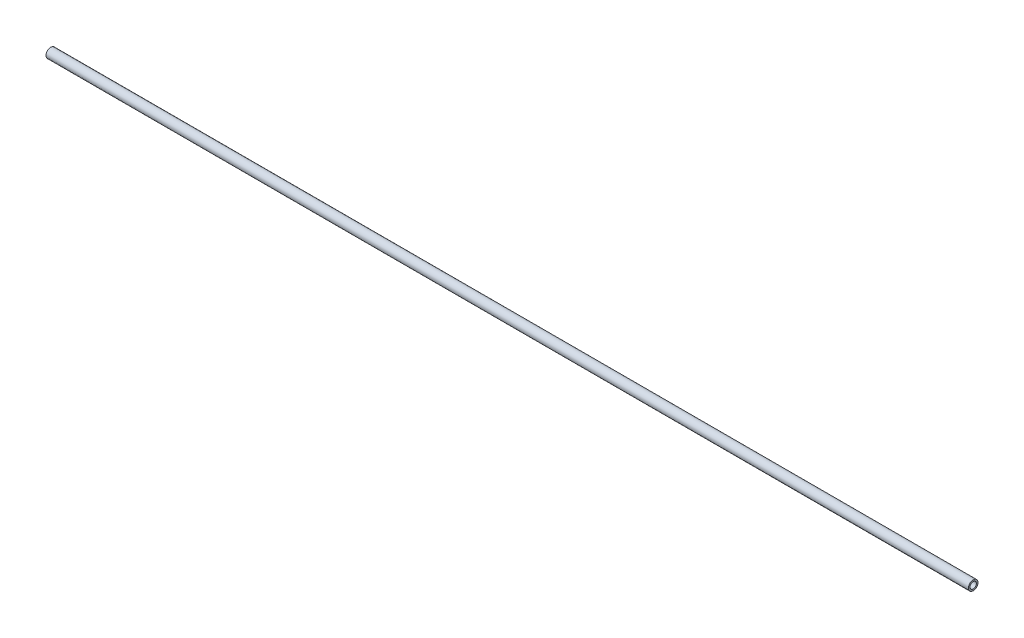
from build123d import *

# Parameters (mm, degrees)
BOSS_EXTRUDE1_DEPTH      = 290
BOSS_EXTRUDE1_DEPTH_BACK = 290
SKETCH1_R                = 3
SKETCH1_R_2              = 2


with BuildPart() as part:
    # Sketch1 → Boss-Extrude1 (new, two sides: drawn at the far end of the back side and taken through both)
    with BuildSketch(Plane(origin=(0, 0, 0), x_dir=(0, 0, -1), z_dir=(1, 0, 0)).offset(-BOSS_EXTRUDE1_DEPTH_BACK)):
        Circle(SKETCH1_R)
        Circle(SKETCH1_R_2, mode=Mode.SUBTRACT)
    extrude(amount=BOSS_EXTRUDE1_DEPTH + BOSS_EXTRUDE1_DEPTH_BACK)


solid = part.part
